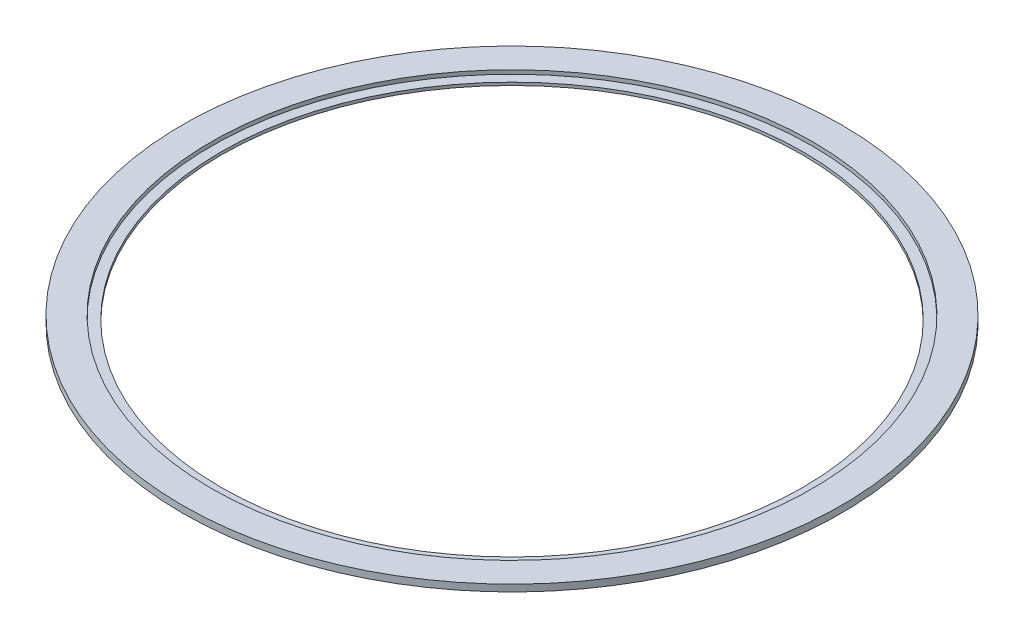
from build123d import *

# Parameters (mm, degrees)
SKETCH_1_R          = 160
SKETCH_1_R_2        = 150
EXTRUDE_1_DEPTH     = 1.5
SKETCH_2_R          = 160
SKETCH_2_R_2        = 152.5
EXTRUDE_2_DEPTH     = 2
SKETCH_3_R          = 170
SKETCH_3_R_2        = 160
EXTRUDE_3_DEPTH     = 3.5
SKETCH_4_R          = 155
SKETCH_4_R_2        = 152.5
CUT_EXTRUDE_1_DEPTH = 2


with BuildPart() as part:
    # ｽｹｯﾁ1 → ﾎﾞｽ - 押し出し1 (new body)
    with BuildSketch(Plane(origin=(0, 0, 0), x_dir=(1, 0, 0), z_dir=(0, 1, 0))):
        Circle(SKETCH_1_R)
        Circle(SKETCH_1_R_2, mode=Mode.SUBTRACT)
    extrude(amount=EXTRUDE_1_DEPTH)

    # ｽｹｯﾁ2 → ﾎﾞｽ - 押し出し2 (add)
    with BuildSketch(Plane(origin=(0, 1.5, 0), x_dir=(1, 0, 0), z_dir=(0, 1, 0))):
        Circle(SKETCH_2_R)
        Circle(SKETCH_2_R_2, mode=Mode.SUBTRACT)
    extrude(amount=EXTRUDE_2_DEPTH)

    # ｽｹｯﾁ3 → ﾎﾞｽ - 押し出し3 (add)
    with BuildSketch(Plane(origin=(0, 3.5, 0), x_dir=(1, 0, 0), z_dir=(0, 1, 0))):
        Circle(SKETCH_3_R)
        Circle(SKETCH_3_R_2, mode=Mode.SUBTRACT)
    extrude(amount=-EXTRUDE_3_DEPTH)

    # ｽｹｯﾁ4 → ｶｯﾄ - 押し出し1 (cut)
    with BuildSketch(Plane(origin=(0, 3.5, 0), x_dir=(1, 0, 0), z_dir=(0, 1, 0))):
        Circle(SKETCH_4_R)
        Circle(SKETCH_4_R_2, mode=Mode.SUBTRACT)
    extrude(amount=-CUT_EXTRUDE_1_DEPTH, mode=Mode.SUBTRACT)


solid = part.part
